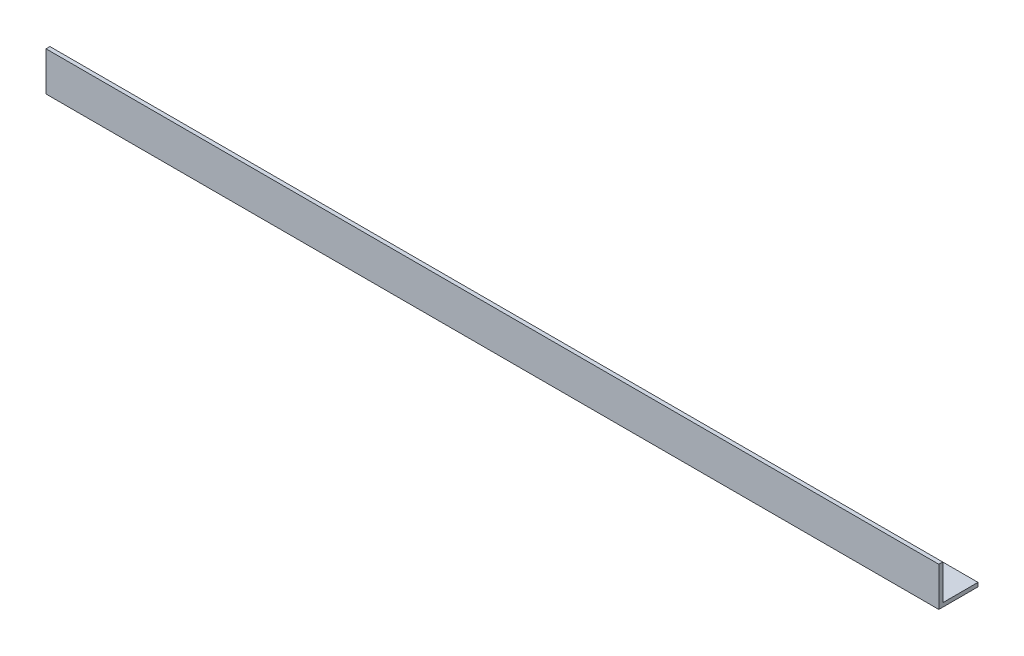
from build123d import *

# Parameters (mm, degrees)
EXTRUDE_1_DEPTH = 342


with BuildPart() as part:
    # Эскиз1 → Бобышка-Вытянуть1 (new body)
    with BuildSketch(Plane(origin=(0, 0, 0), x_dir=(0, 0, -1), z_dir=(1, 0, 0))):
        Polygon((0, 0), (0, 15), (1.5, 15), (1.5, 1.5), (15, 1.5), (15, 0), align=None)
    extrude(amount=EXTRUDE_1_DEPTH)


solid = part.part
